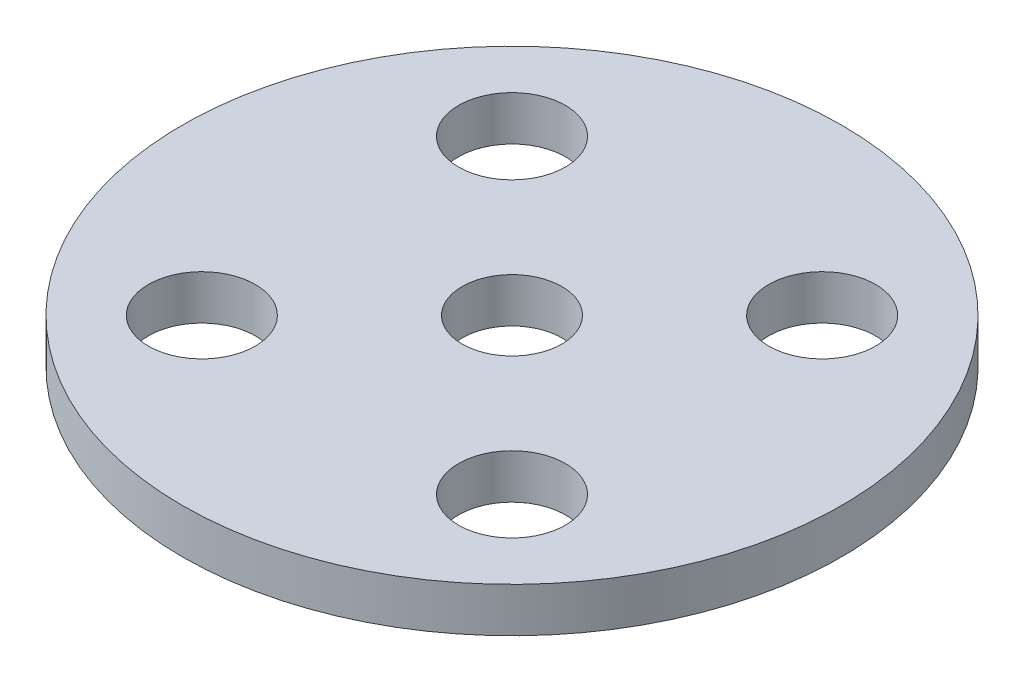
from build123d import *

# Parameters (mm, degrees)
SKETCH1_R           = 23.495
SKETCH1_R_2         = 3.81
SKETCH1_R_3         = 3.556
BOSS_EXTRUDE1_DEPTH = 3.175


with BuildPart() as part:
    # Sketch1 → Boss-Extrude1 (new body)
    with BuildSketch(Plane(origin=(0, 0, 0), x_dir=(1, 0, 0), z_dir=(0, 1, 0))):
        Circle(SKETCH1_R)
        with Locations((-11.055868466, 11.055868466)):
            Circle(SKETCH1_R_2, mode=Mode.SUBTRACT)
        Circle(SKETCH1_R_3, mode=Mode.SUBTRACT)
        with Locations((11.055868466, -11.055868466)):
            Circle(SKETCH1_R_2, mode=Mode.SUBTRACT)
        with Locations((11.055868466, 11.055868466)):
            Circle(SKETCH1_R_2, mode=Mode.SUBTRACT)
        with Locations((-11.055868466, -11.055868466)):
            Circle(SKETCH1_R_2, mode=Mode.SUBTRACT)
    extrude(amount=BOSS_EXTRUDE1_DEPTH)


solid = part.part
